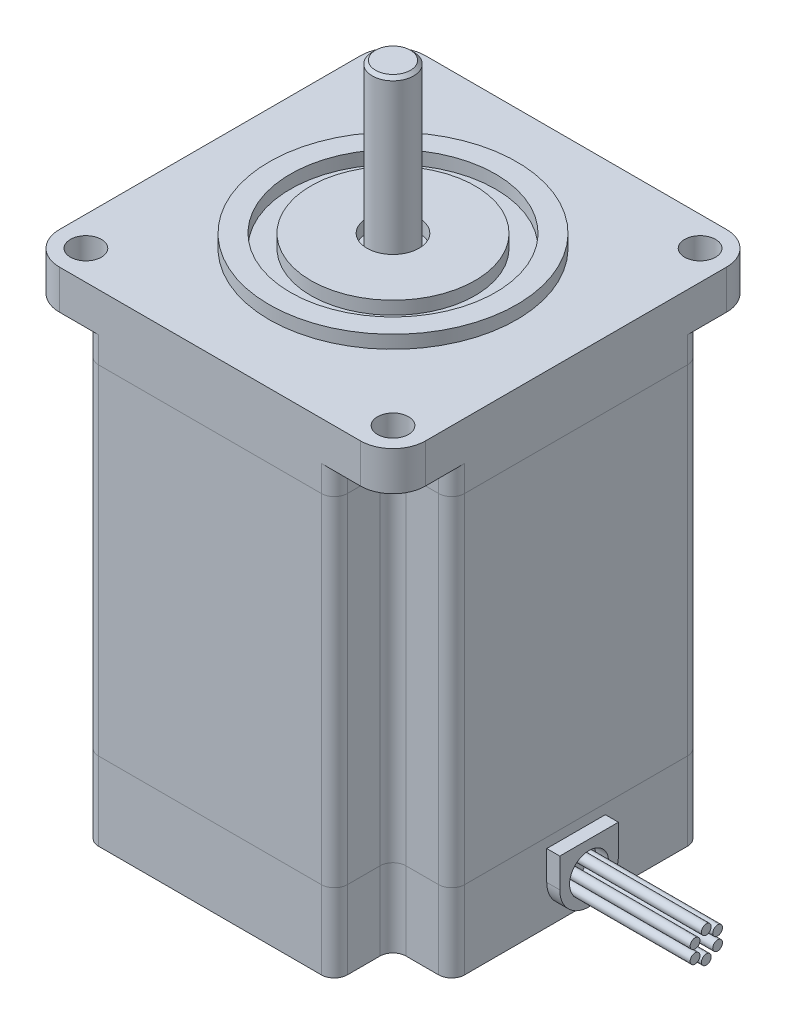
from build123d import *

# Parameters (mm, degrees)
SKETCH1_W             = 56.2
SKETCH1_H             = 56.2
SKETCH1_R             = 2.375
BOSS_EXTRUDE2_DEPTH   = 12
SKETCH2_W             = 56.2
SKETCH2_H             = 56.2
SKETCH2_R             = 2.375
BOSS_EXTRUDE3_DEPTH   = 52
SKETCH3_W             = 56.2
SKETCH3_H             = 56.2
SKETCH3_R             = 2.375
BOSS_EXTRUDE4_DEPTH   = 10
SKETCH4_R             = 3
BOSS_EXTRUDE5_DEPTH   = 2
SKETCH5_R             = 0.75
BOSS_EXTRUDE6_DEPTH   = 20
BOSS_EXTRUDE6_2_DEPTH = 20
BOSS_EXTRUDE6_3_DEPTH = 20
BOSS_EXTRUDE6_4_DEPTH = 20
BOSS_EXTRUDE6_5_DEPTH = 20
BOSS_EXTRUDE6_6_DEPTH = 20
SKETCH6_R             = 19
SKETCH6_R_2           = 15.75
SKETCH6_R_3           = 12.6
SKETCH6_R_4           = 4
BOSS_EXTRUDE7_DEPTH   = 2
SKETCH7_R             = 3.175
BOSS_EXTRUDE8_DEPTH   = 25
SKETCH11_W            = 9
SKETCH11_H            = 9
CUT_EXTRUDE1_DEPTH    = 68
FILLET1_R             = 5
FILLET2_R             = 2
FILLET3_R             = 2
CHAMFER1_SIZE         = 0.5
FILLET4_R             = 2


with BuildPart() as part:
    # Sketch1 → Boss-Extrude2 (new body)
    with BuildSketch(Plane(origin=(0, 0, 0), x_dir=(1, 0, 0), z_dir=(0, 1, 0))):
        Rectangle(SKETCH1_W, SKETCH1_H)
        with Locations(Location((23.57, 23.57, 0), (0, 0, 270))):
            Circle(SKETCH1_R, mode=Mode.SUBTRACT)
        with Locations(Location((23.57, -23.57, 0), (0, 0, 270))):
            Circle(SKETCH1_R, mode=Mode.SUBTRACT)
        with Locations(Location((-23.57, -23.57, 0), (0, 0, 270))):
            Circle(SKETCH1_R, mode=Mode.SUBTRACT)
        with Locations(Location((-23.57, 23.57, 0), (0, 0, 270))):
            Circle(SKETCH1_R, mode=Mode.SUBTRACT)
    extrude(amount=BOSS_EXTRUDE2_DEPTH)


with BuildPart() as body_2:
    # Sketch2 → Boss-Extrude3 (new body)
    with BuildSketch(Plane(origin=(0, 12, 0), x_dir=(1, 0, 0), z_dir=(0, 1, 0))):
        Rectangle(SKETCH2_W, SKETCH2_H)
        with Locations(Location((-23.57, -23.57, 0), (0, 0, 90))):
            Circle(SKETCH2_R, mode=Mode.SUBTRACT)
        with Locations(Location((23.57, -23.57, 0), (0, 0, 90))):
            Circle(SKETCH2_R, mode=Mode.SUBTRACT)
        with Locations(Location((23.57, 23.57, 0), (0, 0, 90))):
            Circle(SKETCH2_R, mode=Mode.SUBTRACT)
        with Locations(Location((-23.57, 23.57, 0), (0, 0, 90))):
            Circle(SKETCH2_R, mode=Mode.SUBTRACT)
    extrude(amount=BOSS_EXTRUDE3_DEPTH)


with BuildPart() as body_3:
    # Sketch3 → Boss-Extrude4 (new body)
    with BuildSketch(Plane(origin=(0, 64, 0), x_dir=(1, 0, 0), z_dir=(0, 1, 0))):
        Rectangle(SKETCH3_W, SKETCH3_H)
        with Locations(Location((23.57, 23.57, 0), (0, 0, 270))):
            Circle(SKETCH3_R, mode=Mode.SUBTRACT)
        with Locations(Location((23.57, -23.57, 0), (0, 0, 270))):
            Circle(SKETCH3_R, mode=Mode.SUBTRACT)
        with Locations(Location((-23.57, -23.57, 0), (0, 0, 270))):
            Circle(SKETCH3_R, mode=Mode.SUBTRACT)
        with Locations(Location((-23.57, 23.57, 0), (0, 0, 270))):
            Circle(SKETCH3_R, mode=Mode.SUBTRACT)
    extrude(amount=BOSS_EXTRUDE4_DEPTH)

    # Sketch6 → Boss-Extrude7 (add)
    with BuildSketch(Plane(origin=(0, 74, 0), x_dir=(1, 0, 0), z_dir=(0, 1, 0))):
        with Locations(Location((0, 0, 0), (0, 0, 270))):
            Circle(SKETCH6_R)
        with Locations(Location((0, 0, 0), (0, 0, 270))):
            Circle(SKETCH6_R_2, mode=Mode.SUBTRACT)
        with Locations(Location((0, 0, 0), (0, 0, 270))):
            Circle(SKETCH6_R_3)
        with Locations(Location((0, 0, 0), (0, 0, 270))):
            Circle(SKETCH6_R_4, mode=Mode.SUBTRACT)
    extrude(amount=BOSS_EXTRUDE7_DEPTH)


with BuildPart() as body_4:
    # Sketch4 → Boss-Extrude5 (new body)
    with BuildSketch(Plane(origin=(28.1, 0, 0), x_dir=(0, 0, -1), z_dir=(1, 0, 0))):
        with BuildLine():
            Line((-4.5, 6), (-4.5, 10.5))
            Line((-4.5, 10.5), (4.5, 10.5))
            Line((4.5, 10.5), (4.5, 6))
            ThreePointArc((4.5, 6), (0, 1.5), (-4.5, 6))
        make_face()
        with Locations((0, 6)):
            Circle(SKETCH4_R, mode=Mode.SUBTRACT)
    extrude(amount=BOSS_EXTRUDE5_DEPTH)


with BuildPart() as body_5:
    # Sketch5 → Boss-Extrude6 (new body)
    with BuildSketch(Plane(origin=(28.1, 0, 0), x_dir=(0, 0, -1), z_dir=(1, 0, 0))):
        with Locations((-1.732050808, 4.5)):
            Circle(SKETCH5_R)
    extrude(amount=BOSS_EXTRUDE6_DEPTH)


with BuildPart() as body_6:
    # Sketch5 → Boss-Extrude6 2 (new body)
    with BuildSketch(Plane(origin=(28.1, 0, 0), x_dir=(0, 0, -1), z_dir=(1, 0, 0))):
        with Locations((0, 3.5)):
            Circle(SKETCH5_R)
    extrude(amount=BOSS_EXTRUDE6_2_DEPTH)


with BuildPart() as body_7:
    # Sketch5 → Boss-Extrude6 3 (new body)
    with BuildSketch(Plane(origin=(28.1, 0, 0), x_dir=(0, 0, -1), z_dir=(1, 0, 0))):
        with Locations((-1.732050808, 6.5)):
            Circle(SKETCH5_R)
    extrude(amount=BOSS_EXTRUDE6_3_DEPTH)


with BuildPart() as body_8:
    # Sketch5 → Boss-Extrude6 4 (new body)
    with BuildSketch(Plane(origin=(28.1, 0, 0), x_dir=(0, 0, -1), z_dir=(1, 0, 0))):
        with Locations((0, 7.5)):
            Circle(SKETCH5_R)
    extrude(amount=BOSS_EXTRUDE6_4_DEPTH)


with BuildPart() as body_9:
    # Sketch5 → Boss-Extrude6 5 (new body)
    with BuildSketch(Plane(origin=(28.1, 0, 0), x_dir=(0, 0, -1), z_dir=(1, 0, 0))):
        with Locations((1.732050808, 6.5)):
            Circle(SKETCH5_R)
    extrude(amount=BOSS_EXTRUDE6_5_DEPTH)


with BuildPart() as body_10:
    # Sketch5 → Boss-Extrude6 6 (new body)
    with BuildSketch(Plane(origin=(28.1, 0, 0), x_dir=(0, 0, -1), z_dir=(1, 0, 0))):
        with Locations((1.732050808, 4.5)):
            Circle(SKETCH5_R)
    extrude(amount=BOSS_EXTRUDE6_6_DEPTH)


with BuildPart() as body_11:
    # Sketch7 → Boss-Extrude8 (new body)
    with BuildSketch(Plane(origin=(0, 74, 0), x_dir=(1, 0, 0), z_dir=(0, 1, 0))):
        with Locations(Location((0, 0, 0), (0, 0, 270))):
            Circle(SKETCH7_R)
    extrude(amount=BOSS_EXTRUDE8_DEPTH)

    # Chamfer1
    chamfer1_edges = [body_11.edges().sort_by_distance(p)[0] for p in [
        (0, 99, -3.175),
    ]]
    chamfer(chamfer1_edges, length=CHAMFER1_SIZE)


with BuildPart() as cut_extrude1_tool:
    # Sketch11 → Cut-Extrude1 (new body)
    with BuildSketch(Plane.XZ):
        with Locations((-23.6, 23.6)):
            Rectangle(SKETCH11_W, SKETCH11_H)
        with Locations((23.6, 23.6)):
            Rectangle(SKETCH11_W, SKETCH11_H)
        with Locations((23.6, -23.6)):
            Rectangle(SKETCH11_W, SKETCH11_H)
        with Locations((-23.6, -23.6)):
            Rectangle(SKETCH11_W, SKETCH11_H)
    extrude(amount=-CUT_EXTRUDE1_DEPTH)


with BuildPart() as part_1:
    add(part.part)

    # Cut-Extrude1: cut by cut_extrude1_tool
    add(cut_extrude1_tool.part, mode=Mode.SUBTRACT)

    # Fillet2
    fillet2_edges = [part_1.edges().sort_by_distance(p)[0] for p in [
        (-19.1, 6, -28.1),
        (19.1, 6, -28.1),
        (28.1, 6, 19.1),
        (-19.1, 6, 28.1),
        (-19.1, 6, 19.1),
        (-28.1, 6, 19.1),
        (19.1, 6, 19.1),
        (19.1, 6, 28.1),
        (19.1, 6, -19.1),
        (28.1, 6, -19.1),
        (-19.1, 6, -19.1),
        (-28.1, 6, -19.1),
    ]]
    fillet(fillet2_edges, radius=FILLET2_R)


with BuildPart() as body_2_1:
    add(body_2.part)

    # Cut-Extrude1: cut by cut_extrude1_tool
    add(cut_extrude1_tool.part, mode=Mode.SUBTRACT)

    # Fillet3
    fillet3_edges = [body_2_1.edges().sort_by_distance(p)[0] for p in [
        (-19.1, 38, -28.1),
        (19.1, 38, -28.1),
        (28.1, 38, 19.1),
        (-19.1, 38, 28.1),
        (-19.1, 38, 19.1),
        (-28.1, 38, 19.1),
        (19.1, 38, 19.1),
        (19.1, 38, 28.1),
        (19.1, 38, -19.1),
        (28.1, 38, -19.1),
        (-28.1, 38, -19.1),
        (-19.1, 38, -19.1),
    ]]
    fillet(fillet3_edges, radius=FILLET3_R)


with BuildPart() as body_3_1:
    add(body_3.part)

    # Cut-Extrude1: cut by cut_extrude1_tool
    add(cut_extrude1_tool.part, mode=Mode.SUBTRACT)

    # Fillet1
    fillet1_edges = [body_3_1.edges().sort_by_distance(p)[0] for p in [
        (-28.1, 71, -28.1),
        (28.1, 71, -28.1),
        (28.1, 71, 28.1),
        (-28.1, 71, 28.1),
    ]]
    fillet(fillet1_edges, radius=FILLET1_R)

    # Fillet4
    fillet4_edges = [body_3_1.edges().sort_by_distance(p)[0] for p in [
        (-19.1, 66, 19.1),
        (-19.1, 66, 28.1),
        (-28.1, 66, 19.1),
        (19.1, 66, 19.1),
        (28.1, 66, 19.1),
        (19.1, 66, 28.1),
        (19.1, 66, -19.1),
        (19.1, 66, -28.1),
        (28.1, 66, -19.1),
        (-28.1, 66, -19.1),
        (-19.1, 66, -28.1),
        (-19.1, 66, -19.1),
    ]]
    fillet(fillet4_edges, radius=FILLET4_R)


solid = Compound([body_4.part, body_5.part, body_6.part, body_7.part, body_8.part, body_9.part, body_10.part, body_11.part, part_1.part, body_2_1.part, body_3_1.part])
